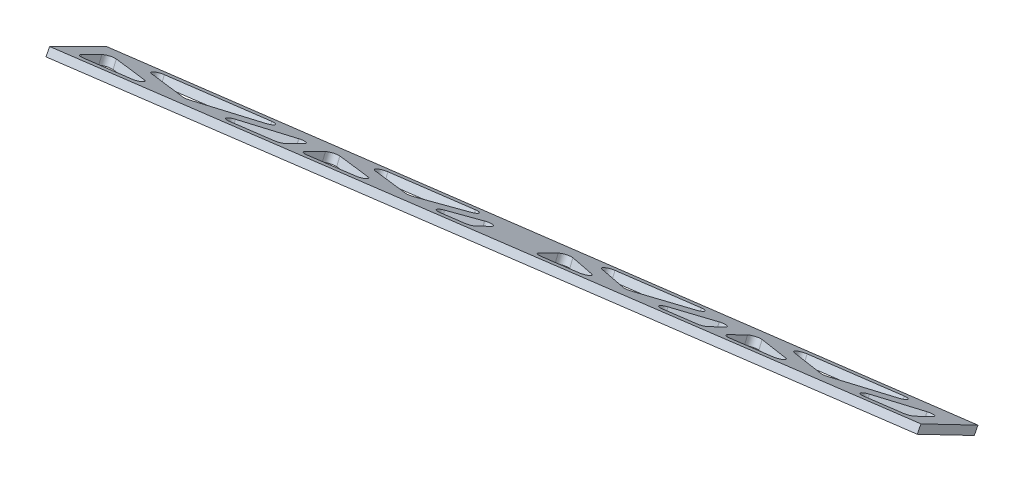
from build123d import *

# Parameters (mm, degrees)
CUT_EXTRUDE1_DEPTH      = 30.840453091
CUT_EXTRUDE1_DEPTH_BACK = 34.270570064
FILLET1_R               = 2.54


with BuildPart() as part:
    # Sketch1_4 → Loft3 section 0
    with BuildSketch(Plane(origin=(0, 0, 0), x_dir=(0, 0, -1), z_dir=(1, 0, 0))):
        Polygon((146.053031758, -42.941582115), (168.594795862, -54.647515272), (170.058037507, -51.829794759), (147.516273403, -40.123861602), align=None)
    # Sketch2_4 → Loft3 section 1
    with BuildSketch(Plane(origin=(-301.244, 0, 0), x_dir=(0, 0, -1), z_dir=(1, 0, 0))):
        Polygon((125.828368959, -54.427320521), (103.140917658, -43.006306842), (104.568544368, -40.17037543), (127.255995669, -51.591389108), align=None)
    loft()

    # Sketch3 → Cut-Extrude1 (cut, two sides)
    with BuildSketch(Plane(origin=(-2.088531267, 28.612784475, -14.858612705), x_dir=(0.997908413, 0.057369347, -0.02979189), z_dir=(-0.064643629, 0.885614805, -0.459899574))) as cut_extrude1_sk:
        Polygon((-293.44993503, 115.290950046), (-293.437214288, 130.909344128), (-264.280543286, 118.971592888), align=None)
        Polygon((-209.545217662, 144.92540256), (-161.675769383, 150.966280016), (-181.047284261, 133.257361315), align=None)
        Polygon((-222.30042402, 124.268714845), (-250.764804664, 120.677031488), (-222.30042402, 139.508802177), align=None)
        Polygon((-134.877534747, 150.77057696), (-134.877534747, 135.299881846), (-110.907832924, 138.324419081), align=None)
        Polygon((-156.216534162, 132.60729106), (-174.930134494, 130.245977539), (-156.216534162, 147.35344843), align=None)
        Polygon((-287.029214558, 135.147321823), (-229.410973685, 142.418446619), (-258.226377305, 123.354442379), align=None)
        Polygon((-129.334803294, 155.047543118), (-82.065784612, 161.012649456), (-105.700293953, 142.775432399), align=None)
        Polygon((-4.257091232, 151.781788795), (-30.211161805, 148.506860578), (-4.257091232, 166.937592798), align=None)
        Polygon((-69.502442128, 159.10626395), (-69.502442128, 143.549020835), (-42.859712466, 146.910845212), align=None)
        Polygon((-75.852442128, 157.786399831), (-75.852442128, 142.747767169), (-99.151772658, 139.80781851), align=None)
        Polygon((-215.95042402, 140.686281161), (-215.95042402, 125.069968511), (-186.794642287, 128.748894019), align=None)
        Polygon((-63.522631135, 163.352699777), (-10.925846423, 169.990142707), (-37.224238779, 151.314897683), align=None)
    extrude(amount=CUT_EXTRUDE1_DEPTH, mode=Mode.SUBTRACT)
    extrude(cut_extrude1_sk.sketch, amount=-CUT_EXTRUDE1_DEPTH_BACK, mode=Mode.SUBTRACT)

    # Fillet1
    fillet1_edges = [part.edges().sort_by_distance(p)[0] for p in [
        (-39.130548255, -44.68804373, -147.294734032),
        (-107.459990626, -44.727374209, -137.652062892),
        (-182.645638077, -44.714798919, -126.933655987),
        (-259.659351162, -44.632777713, -115.817666791),
        (-294.804589244, -43.00101792, -107.579117522),
        (-252.211296848, -42.999399407, -113.648980298),
        (-217.471819613, -42.998085844, -118.599612215),
        (-176.539785008, -42.996545638, -124.432725288),
        (-136.573357631, -42.995049603, -130.128228147),
        (-100.924458329, -42.993721715, -135.208448794),
        (-71.338917006, -42.992624359, -139.424595506),
        (-32.132169635, -42.991176679, -145.011827958),
        (-288.412504414, -51.575419034, -125.500539953),
        (-211.091241939, -51.6273954, -136.491464074),
        (-131.049285819, -51.681231962, -147.869107892),
        (-65.375330922, -51.725428328, -157.204385222),
        (-71.341911227, -50.12136933, -153.252500082),
        (-136.579058191, -50.046831028, -143.898577817),
        (-217.48098276, -50.069539802, -132.523827398),
        (-294.80431785, -50.028045071, -121.528748887),
        (-223.817360536, -49.895844931, -131.28724691),
        (-157.872727487, -49.705764807, -140.225282066),
        (-77.678406788, -49.880440696, -151.890394881),
        (-6.234192357, -49.971489575, -162.154653179),
        (-12.889007684, -51.760765274, -164.665087842),
        (-83.879540638, -51.712973447, -154.574090544),
        (-163.322329555, -51.659521143, -143.281625878),
        (-230.915275459, -51.614066591, -133.673554418),
        (-265.697956139, -42.999910938, -111.727030969),
        (-223.808157571, -42.998324997, -117.696637519),
        (-188.37876644, -42.996990285, -122.745584643),
        (-157.866446684, -42.995845688, -127.093810583),
        (-112.655225873, -42.994157995, -133.536731692),
        (-77.675255291, -42.992859023, -138.521623141),
        (-44.753507719, -42.991641899, -143.213200488),
        (-6.233937469, -42.990224491, -148.702502856),
    ]]
    fillet(fillet1_edges, radius=FILLET1_R)


solid = part.part
